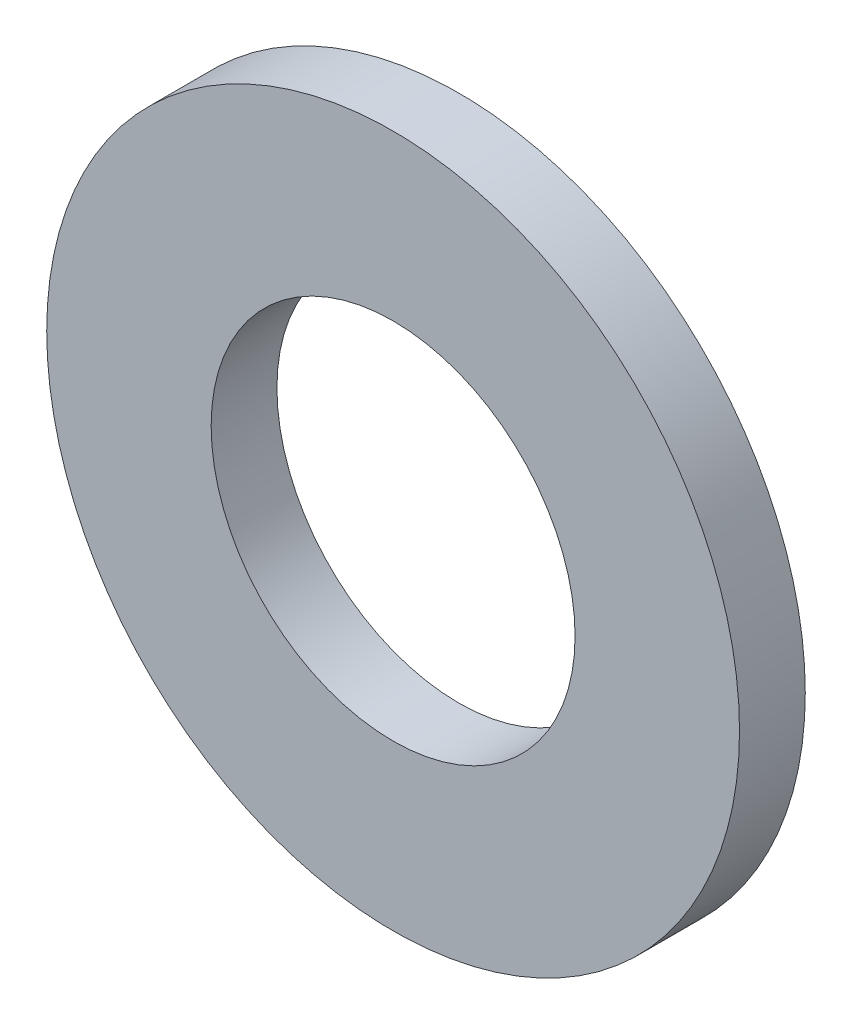
from build123d import *

# Parameters (mm, degrees)
SKETCH2_R           = 7.9
SKETCH2_R_2         = 4.15
BOSS_EXTRUDE1_DEPTH = 1.5


with BuildPart() as part:
    # Sketch2 → Boss-Extrude1 (new body)
    with BuildSketch(Plane.XY):
        Circle(SKETCH2_R)
        Circle(SKETCH2_R_2, mode=Mode.SUBTRACT)
    extrude(amount=BOSS_EXTRUDE1_DEPTH)


solid = part.part
